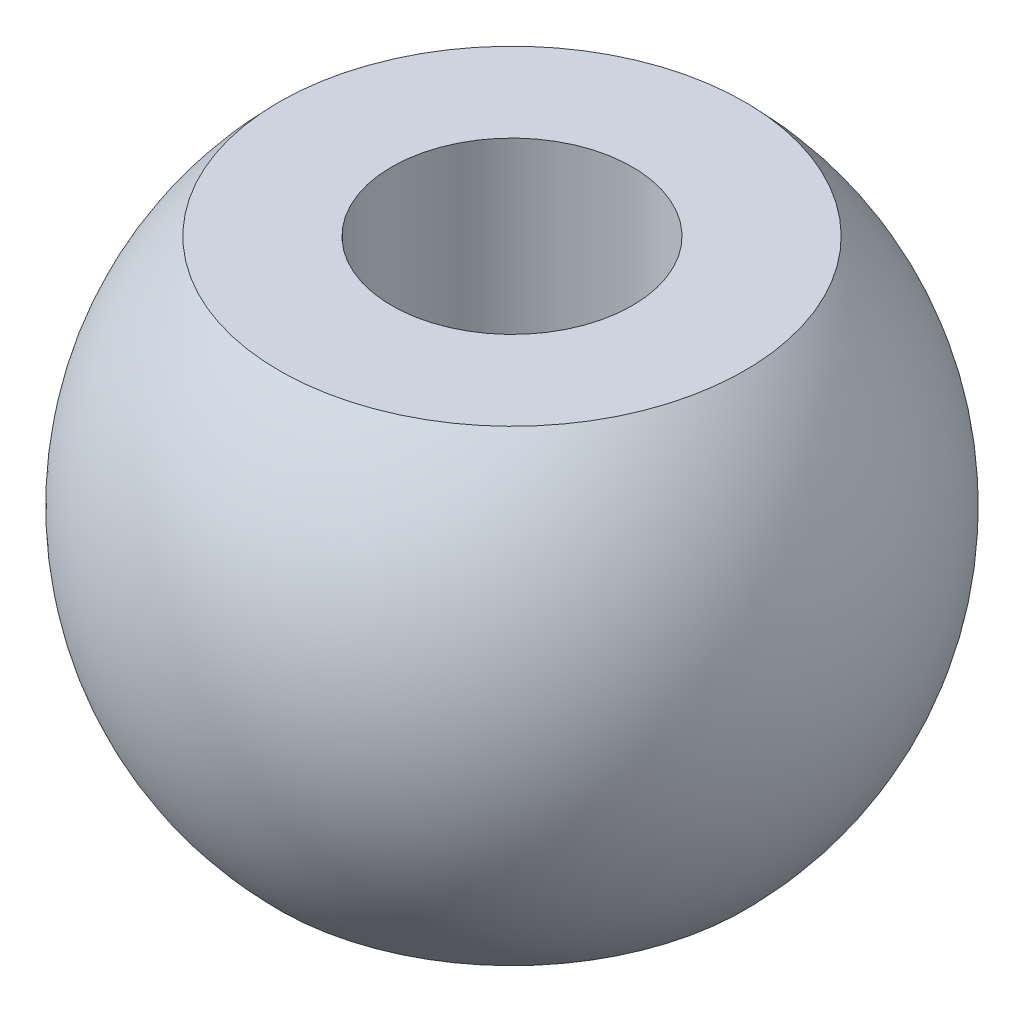
from build123d import *

# Parameters (mm, degrees)
SKETCH3_R          = 3.1
CUT_EXTRUDE1_DEPTH = 13.041594579


with BuildPart() as part:
    # Sketch1 → Revolve2 (revolve)
    with BuildSketch(Plane.XY):
        with BuildLine():
            Line((0, 6.020797289), (0, -6.020797289))
            Line((0, -6.020797289), (-6, -6.020797289))
            ThreePointArc((-6, -6.020797289), (-8.5, 0), (-6, 6.020797289))
            Line((-6, 6.020797289), (0, 6.020797289))
        make_face()
    revolve(axis=Axis((0, 6.020797289, 0), (0, -1, 0)))

    # Sketch3 → Cut-Extrude1 (cut, through all)
    with BuildSketch(Plane(origin=(0, 6.020797289, 0), x_dir=(1, 0, 0), z_dir=(0, 1, 0))):
        Circle(SKETCH3_R)
    extrude(amount=-CUT_EXTRUDE1_DEPTH, mode=Mode.SUBTRACT)


solid = part.part
